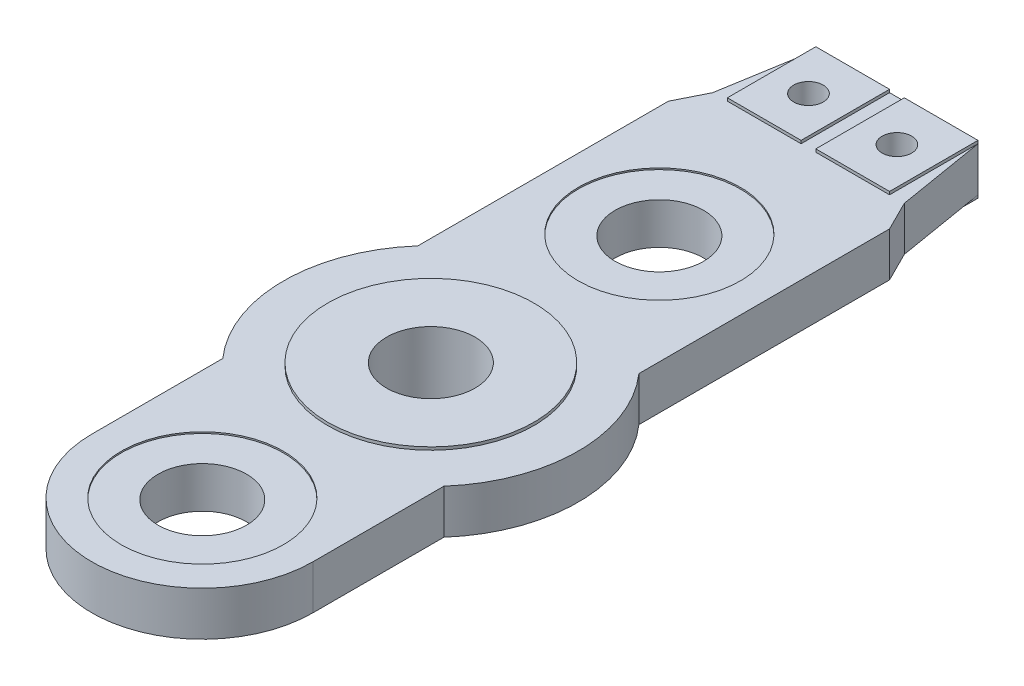
from build123d import *

# Parameters (mm, degrees)
SKETCH1_R           = 1.5
SKETCH1_R_2         = 0.5
BOSS_EXTRUDE1_DEPTH = 1.5
SKETCH2_R           = 3.5
SKETCH2_R_2         = 1.5
BOSS_EXTRUDE2_DEPTH = 0.1
SKETCH3_R           = 2.75
CUT_EXTRUDE1_DEPTH  = 0.05
SKETCH4_R           = 2.75
CUT_EXTRUDE2_DEPTH  = 0.05
SKETCH5_R           = 2.75
SKETCH5_R_2         = 1.5
BOSS_EXTRUDE3_DEPTH = 1.5
FILLET1_R           = 0.5
SKETCH6_W           = 2.5
SKETCH6_H           = 3
SKETCH6_R           = 0.5
BOSS_EXTRUDE4_DEPTH = 0.1
SKETCH7_W           = 2.5
SKETCH7_H           = 3
SKETCH7_R           = 0.5
BOSS_EXTRUDE5_DEPTH = 0.1


with BuildPart() as part:
    # Sketch1 → Boss-Extrude1 (new body)
    with BuildSketch(Plane(origin=(0, 0, 0), x_dir=(1, 0, 0), z_dir=(0, 1, 0))):
        with BuildLine():
            Line((-3.75, -7.75), (-3.75, -3.307189139))
            ThreePointArc((-3.75, -3.307189139), (-5, 0), (-3.75, 3.307189139))
            Line((-3.75, 3.307189139), (-3.75, 11.807189139))
            Line((-3.75, 11.807189139), (-3.25, 12.807189139))
            Line((-3.25, 12.807189139), (-2.75, 15.807189139))
            Line((-2.75, 15.807189139), (2.75, 15.807189139))
            Line((2.75, 15.807189139), (3.25, 12.807189139))
            Line((3.25, 12.807189139), (3.75, 11.807189139))
            Line((3.75, 11.807189139), (3.75, 3.307189139))
            ThreePointArc((3.75, 3.307189139), (5, 0), (3.75, -3.307189139))
            Line((3.75, -3.307189139), (3.75, -7.75))
            ThreePointArc((3.75, -7.75), (0, -11.5), (-3.75, -7.75))
        make_face()
        with Locations((0, -7.75)):
            Circle(SKETCH1_R, mode=Mode.SUBTRACT)
        with Locations((0, 7.75)):
            Circle(SKETCH1_R, mode=Mode.SUBTRACT)
        with Locations((-1.5, 14.307189139)):
            Circle(SKETCH1_R_2, mode=Mode.SUBTRACT)
        with Locations((1.5, 14.307189139)):
            Circle(SKETCH1_R_2, mode=Mode.SUBTRACT)
        Circle(SKETCH1_R, mode=Mode.SUBTRACT)
    extrude(amount=BOSS_EXTRUDE1_DEPTH)

    # Sketch2 → Boss-Extrude2 (add)
    with BuildSketch(Plane(origin=(0, 1.5, 0), x_dir=(1, 0, 0), z_dir=(0, 1, 0))):
        Circle(SKETCH2_R)
        Circle(SKETCH2_R_2, mode=Mode.SUBTRACT)
    extrude(amount=BOSS_EXTRUDE2_DEPTH)

    # Sketch3 → Cut-Extrude1 (cut)
    with BuildSketch(Plane(origin=(0, 1.5, 0), x_dir=(1, 0, 0), z_dir=(0, 1, 0))):
        with Locations((0, -7.75)):
            Circle(SKETCH3_R)
        with Locations((0, 7.75)):
            Circle(SKETCH3_R)
    extrude(amount=-CUT_EXTRUDE1_DEPTH, mode=Mode.SUBTRACT)

    # Sketch4 → Cut-Extrude2 (cut)
    with BuildSketch(Plane.XZ):
        with Locations((0, -7.75)):
            Circle(SKETCH4_R)
        with Locations((0, 7.75)):
            Circle(SKETCH4_R)
    extrude(amount=-CUT_EXTRUDE2_DEPTH, mode=Mode.SUBTRACT)

    # Sketch5 → Boss-Extrude3 (add)
    with BuildSketch(Plane.XZ):
        Circle(SKETCH5_R)
        Circle(SKETCH5_R_2, mode=Mode.SUBTRACT)
    extrude(amount=BOSS_EXTRUDE3_DEPTH)

    # Fillet1
    fillet1_edges = [part.edges().sort_by_distance(p)[0] for p in [
        (-2.75, 0, 0),
    ]]
    fillet(fillet1_edges, radius=FILLET1_R)

    # Sketch6 → Boss-Extrude4 (add)
    with BuildSketch(Plane(origin=(0, 1.5, 0), x_dir=(1, 0, 0), z_dir=(0, 1, 0))):
        with Locations((-1.5, 14.307189139)):
            Rectangle(SKETCH6_W, SKETCH6_H)
        with Locations((-1.5, 14.307189139)):
            Circle(SKETCH6_R, mode=Mode.SUBTRACT)
        with Locations((1.5, 14.307189139)):
            Rectangle(SKETCH6_W, SKETCH6_H)
        with Locations((1.5, 14.307189139)):
            Circle(SKETCH6_R, mode=Mode.SUBTRACT)
    extrude(amount=BOSS_EXTRUDE4_DEPTH)

    # Sketch7 → Boss-Extrude5 (add)
    with BuildSketch(Plane.XZ):
        with Locations((-1.5, -14.307189139)):
            Rectangle(SKETCH7_W, SKETCH7_H)
        with Locations((-1.5, -14.307189139)):
            Circle(SKETCH7_R, mode=Mode.SUBTRACT)
        with Locations((1.5, -14.307189139)):
            Rectangle(SKETCH7_W, SKETCH7_H)
        with Locations((1.5, -14.307189139)):
            Circle(SKETCH7_R, mode=Mode.SUBTRACT)
    extrude(amount=BOSS_EXTRUDE5_DEPTH)


solid = part.part
